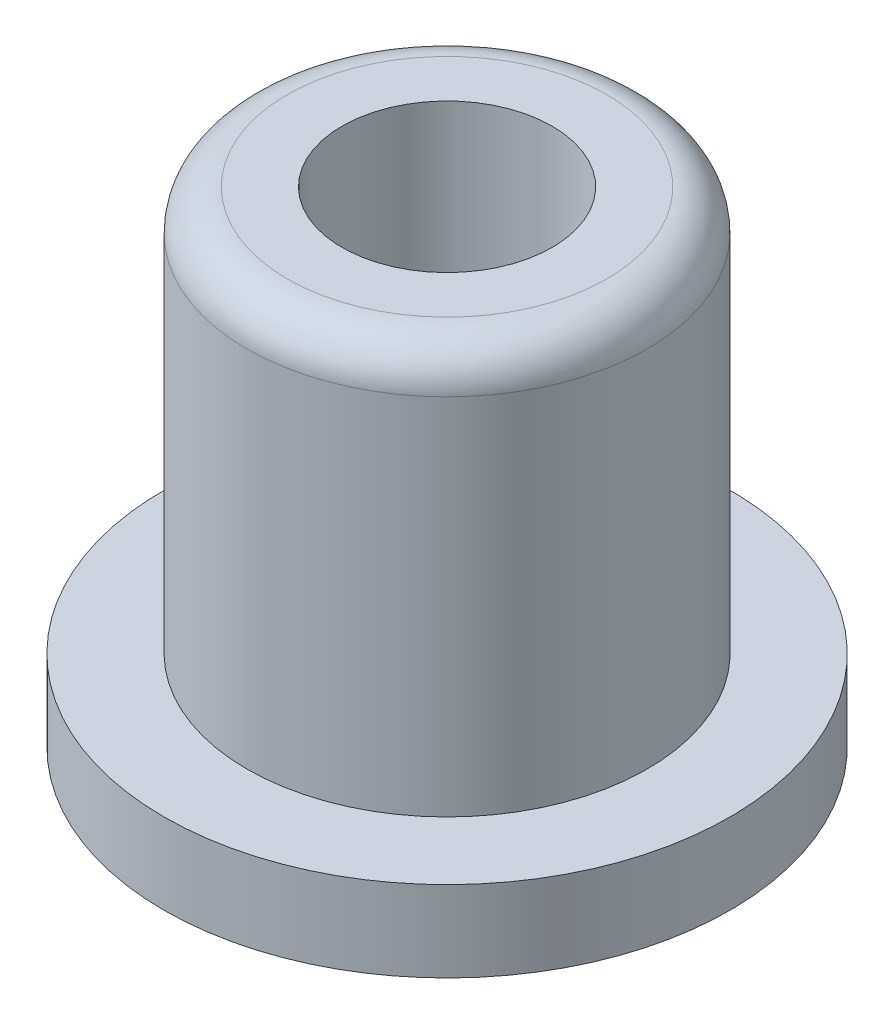
from build123d import *

# Parameters (mm, degrees)
SKETCH1_R           = 7
BOSS_EXTRUDE1_DEPTH = 2
SKETCH2_R           = 4.95
BOSS_EXTRUDE2_DEPTH = 10
SKETCH3_R           = 2.6
CUT_EXTRUDE1_DEPTH  = 13
FILLET1_R           = 1


with BuildPart() as part:
    # Sketch1 → Boss-Extrude1 (new body)
    with BuildSketch(Plane(origin=(0, 0, 0), x_dir=(1, 0, 0), z_dir=(0, 1, 0))):
        Circle(SKETCH1_R)
    extrude(amount=BOSS_EXTRUDE1_DEPTH)

    # Sketch2 → Boss-Extrude2 (add)
    with BuildSketch(Plane(origin=(0, 2, 0), x_dir=(1, 0, 0), z_dir=(0, 1, 0))):
        Circle(SKETCH2_R)
    extrude(amount=BOSS_EXTRUDE2_DEPTH)

    # Sketch3 → Cut-Extrude1 (cut, through all)
    with BuildSketch(Plane.XZ):
        Circle(SKETCH3_R)
    extrude(amount=-CUT_EXTRUDE1_DEPTH, mode=Mode.SUBTRACT)

    # Fillet1
    fillet1_edges = [part.edges().sort_by_distance(p)[0] for p in [
        (-4.95, 12, 0),
    ]]
    fillet(fillet1_edges, radius=FILLET1_R)


solid = part.part
